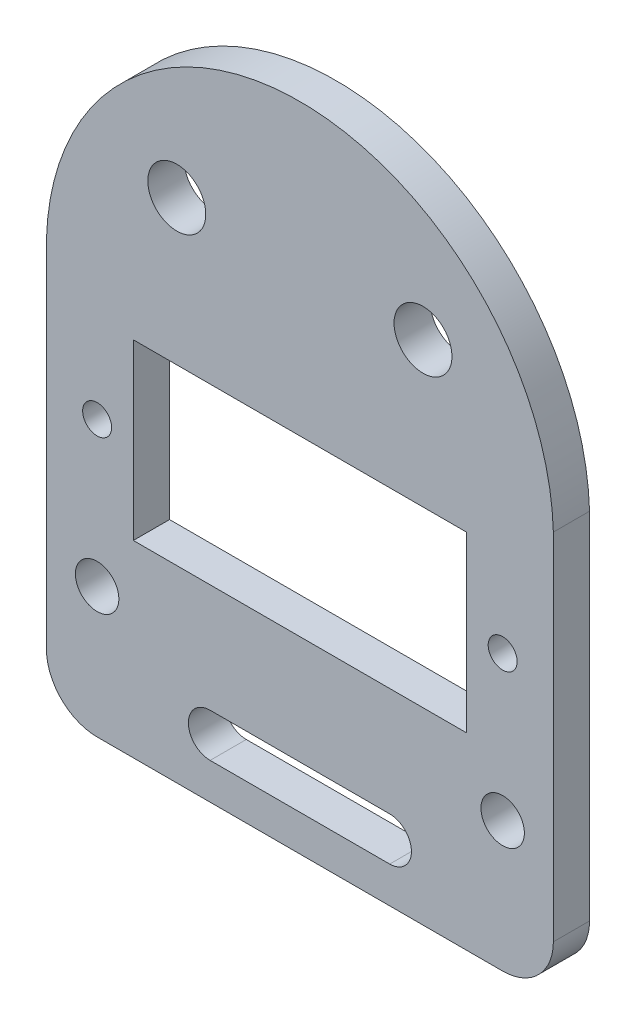
from build123d import *

# Parameters (mm, degrees)
SKETCH1_R           = 1
SKETCH1_R_2         = 1.5
SKETCH1_R_3         = 2
SKETCH1_W           = 23
SKETCH1_H           = 12
BOSS_EXTRUDE1_DEPTH = 2.5
FILLET1_R           = 3.5


with BuildPart() as part:
    # Sketch1 → Boss-Extrude1 (new body)
    with BuildSketch(Plane.XY):
        with BuildLine():
            Line((-17.5, 9), (-17.5, -19))
            Line((-17.5, -19), (17.5, -19))
            Line((17.5, -19), (17.5, 9))
            ThreePointArc((17.5, 9), (0, 26), (-17.5, 9))
        make_face()
        with Locations((-14, 0)):
            Circle(SKETCH1_R, mode=Mode.SUBTRACT)
        with Locations((-14, -10)):
            Circle(SKETCH1_R_2, mode=Mode.SUBTRACT)
        with Locations((-8.5, 16)):
            Circle(SKETCH1_R_3, mode=Mode.SUBTRACT)
        with Locations((14, -10)):
            Circle(SKETCH1_R_2, mode=Mode.SUBTRACT)
        with Locations((14, 0)):
            Circle(SKETCH1_R, mode=Mode.SUBTRACT)
        with Locations((8.5, 16)):
            Circle(SKETCH1_R_3, mode=Mode.SUBTRACT)
        Rectangle(SKETCH1_W, SKETCH1_H, mode=Mode.SUBTRACT)
        with BuildLine():
            Line((-6.2, -13.5), (6.2, -13.5))
            ThreePointArc((6.2, -13.5), (7.7, -15), (6.2, -16.5))
            Line((6.2, -16.5), (-6.2, -16.5))
            ThreePointArc((-6.2, -16.5), (-7.7, -15), (-6.2, -13.5))
        make_face(mode=Mode.SUBTRACT)
    extrude(amount=BOSS_EXTRUDE1_DEPTH)

    # Fillet1
    fillet1_edges = [part.edges().sort_by_distance(p)[0] for p in [
        (17.5, -19, 1.25),
        (-17.5, -19, 1.25),
    ]]
    fillet(fillet1_edges, radius=FILLET1_R)


solid = part.part
